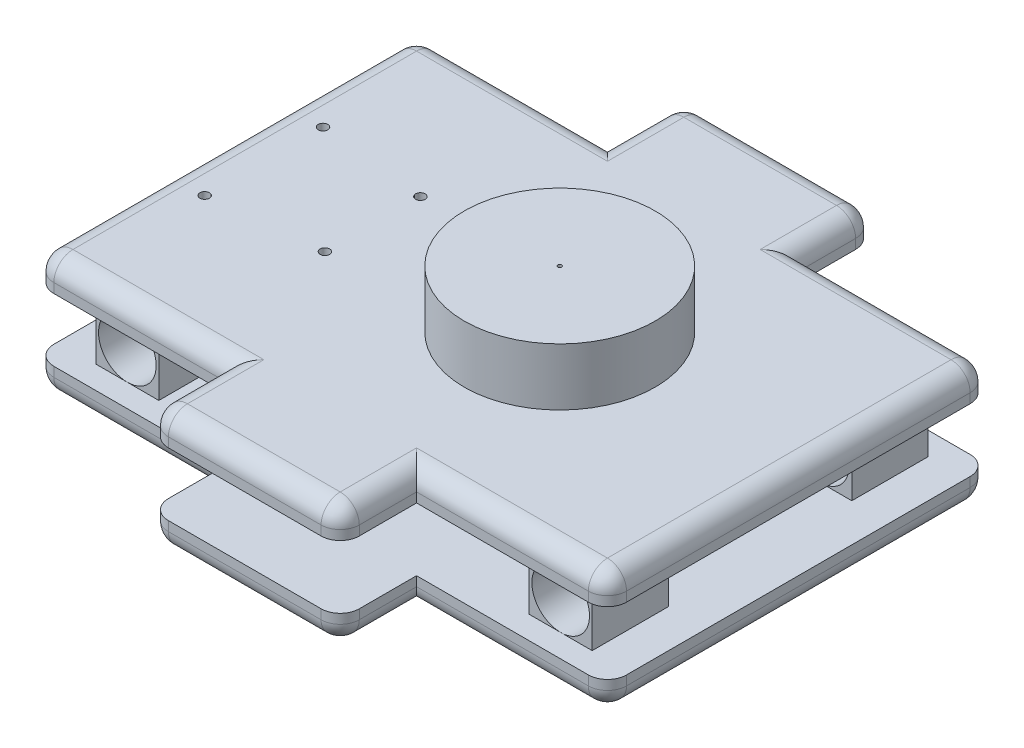
from build123d import *

# Parameters (mm, degrees)
SKETCH1_W                = 300
SKETCH1_H                = 200
BOSS_EXTRUDE1_DEPTH      = 15
SKETCH3_W                = 33
SKETCH3_H                = 40
BOSS_EXTRUDE2_DEPTH      = 33
SKETCH4_R                = 15.1
CUT_EXTRUDE1_DEPTH       = 222
SKETCH5_W                = 300
SKETCH5_H                = 200
BOSS_EXTRUDE3_DEPTH      = 15
SKETCH6_W                = 100
SKETCH6_H                = 15
BOSS_EXTRUDE4_DEPTH      = 40
BOSS_EXTRUDE4_DEPTH_BACK = 240
FILLET1_R                = 10
BOSS_EXTRUDE7_DEPTH      = 34
FILLET2_R                = 10
FILLET3_R                = 10
SKETCH12_R               = 1
CUT_EXTRUDE4_DEPTH       = 1
SKETCH13_R               = 2.5
CUT_EXTRUDE5_DEPTH       = 27
SKETCH14_R               = 2.5
CUT_EXTRUDE6_DEPTH       = 32
SKETCH15_R               = 50
BOSS_EXTRUDE9_DEPTH      = 30
SKETCH16_R               = 1
CUT_EXTRUDE7_DEPTH       = 63


with BuildPart() as part:
    # Sketch1 → Boss-Extrude1 (new body)
    with BuildSketch(Plane(origin=(0, 0, 0), x_dir=(1, 0, 0), z_dir=(0, 1, 0))):
        with Locations((150, -100)):
            Rectangle(SKETCH1_W, SKETCH1_H)
    extrude(amount=BOSS_EXTRUDE1_DEPTH)

    # Sketch3 → Boss-Extrude2 (add)
    with BuildSketch(Plane(origin=(0, 15, 0), x_dir=(1, 0, 0), z_dir=(0, 1, 0))):
        with Locations((263.5, -168)):
            Rectangle(SKETCH3_W, SKETCH3_H)
        with Locations((263.5, -32)):
            Rectangle(SKETCH3_W, SKETCH3_H)
        with Locations((36.5, -32)):
            Rectangle(SKETCH3_W, SKETCH3_H)
        with Locations((36.5, -168)):
            Rectangle(SKETCH3_W, SKETCH3_H)
    extrude(amount=BOSS_EXTRUDE2_DEPTH)

    # Sketch4 → Cut-Extrude1 (cut)
    with BuildSketch(Plane.XY.offset(188)):
        with Locations((36.5, 30.1)):
            Circle(SKETCH4_R)
        with Locations((263.5, 30.1)):
            Circle(SKETCH4_R)
    extrude(amount=-CUT_EXTRUDE1_DEPTH, mode=Mode.SUBTRACT)

    # Sketch5 → Boss-Extrude3 (add)
    with BuildSketch(Plane(origin=(0, 48, 0), x_dir=(1, 0, 0), z_dir=(0, 1, 0))):
        with Locations((150, -100)):
            Rectangle(SKETCH5_W, SKETCH5_H)
    extrude(amount=BOSS_EXTRUDE3_DEPTH)

    # Sketch6 → Boss-Extrude4 (add, two sides)
    with BuildSketch(Plane(origin=(0, 0, 0), x_dir=(-1, 0, 0), z_dir=(0, 0, -1))) as boss_extrude4_sk:
        with Locations((-150, 55.5)):
            Rectangle(SKETCH6_W, SKETCH6_H)
        with Locations((-150, 7.5)):
            Rectangle(SKETCH6_W, SKETCH6_H)
    extrude(amount=BOSS_EXTRUDE4_DEPTH)
    extrude(boss_extrude4_sk.sketch, amount=-BOSS_EXTRUDE4_DEPTH_BACK)

    # Fillet1
    fillet1_edges = [part.edges().sort_by_distance(p)[0] for p in [
        (100, 55.5, 240),
        (200, 55.5, 240),
        (100, 55.5, -40),
        (200, 55.5, -40),
        (200, 7.5, 240),
        (100, 7.5, 240),
        (200, 7.5, -40),
        (100, 7.5, -40),
        (0, 7.5, 0),
        (300, 7.5, 0),
        (300, 7.5, 200),
        (0, 7.5, 200),
        (0, 55.5, 0),
        (0, 55.5, 200),
        (300, 55.5, 200),
        (300, 55.5, 0),
    ]]
    fillet(fillet1_edges, radius=FILLET1_R)

    # Sketch11 → Boss-Extrude7 (add)
    with BuildSketch(Plane(origin=(0, 15, 0), x_dir=(1, 0, 0), z_dir=(0, 1, 0))):
        Polygon((0, -82.3), (0, -100), (0, -117.7), (10, -117.7), (10, -82.3), align=None)
    extrude(amount=BOSS_EXTRUDE7_DEPTH)

    # Fillet2
    fillet2_edges = [part.edges().sort_by_distance(p)[0] for p in [
        (245, 63, 200),
        (55, 63, 0),
        (200, 63, -15),
        (100, 63, -15),
        (245, 63, 0),
        (300, 63, 100),
        (150, 63, -40),
        (0, 63, 100),
        (55, 63, 200),
        (100, 63, 215),
        (150, 63, 240),
        (200, 63, 215),
        (102.928932188, 63, -37.071067812),
        (197.071067812, 63, -37.071067812),
        (102.928932188, 63, 237.071067812),
        (197.071067812, 63, 237.071067812),
        (297.071067812, 63, 197.071067812),
        (2.928932188, 63, 197.071067812),
        (2.928932188, 63, 2.928932188),
        (297.071067812, 63, 2.928932188),
    ]]
    fillet(fillet2_edges, radius=FILLET2_R)

    # Fillet3
    fillet3_edges = [part.edges().sort_by_distance(p)[0] for p in [
        (55, 0, 0),
        (245, 0, 200),
        (100, 0, -15),
        (200, 0, -15),
        (245, 0, 0),
        (150, 0, -40),
        (300, 0, 100),
        (200, 0, 215),
        (150, 0, 240),
        (100, 0, 215),
        (55, 0, 200),
        (0, 0, 100),
        (197.071067812, 0, -37.071067812),
        (102.928932188, 0, -37.071067812),
        (102.928932188, 0, 237.071067812),
        (197.071067812, 0, 237.071067812),
        (297.071067812, 0, 197.071067812),
        (2.928932188, 0, 197.071067812),
        (2.928932188, 0, 2.928932188),
        (297.071067812, 0, 2.928932188),
    ]]
    fillet(fillet3_edges, radius=FILLET3_R)

    # Sketch12 → Cut-Extrude4 (cut)
    with BuildSketch(Plane.ZY):
        with Locations((100, 31.5)):
            Circle(SKETCH12_R)
    extrude(amount=-CUT_EXTRUDE4_DEPTH, mode=Mode.SUBTRACT)

    # Sketch13 → Cut-Extrude5 (cut)
    with BuildSketch(Plane(origin=(0, 63, 0), x_dir=(1, 0, 0), z_dir=(0, 1, 0))):
        with Locations((150, -100)):
            Circle(SKETCH13_R)
    extrude(amount=-CUT_EXTRUDE5_DEPTH, mode=Mode.SUBTRACT)

    # Sketch14 → Cut-Extrude6 (cut)
    with BuildSketch(Plane(origin=(0, 63, 0), x_dir=(1, 0, 0), z_dir=(0, 1, 0))):
        with Locations((20, -131)):
            Circle(SKETCH14_R)
        with Locations((20, -69)):
            Circle(SKETCH14_R)
        with Locations((77, -75)):
            Circle(SKETCH14_R)
        with Locations((77, -125)):
            Circle(SKETCH14_R)
    extrude(amount=-CUT_EXTRUDE6_DEPTH, mode=Mode.SUBTRACT)

    # Sketch15 → Boss-Extrude9 (add)
    with BuildSketch(Plane(origin=(0, 63, 0), x_dir=(1, 0, 0), z_dir=(0, 1, 0))):
        with Locations((175, -100)):
            Circle(SKETCH15_R)
    extrude(amount=BOSS_EXTRUDE9_DEPTH)

    # Sketch16 → Cut-Extrude7 (cut)
    with BuildSketch(Plane(origin=(0, 93, 0), x_dir=(1, 0, 0), z_dir=(0, 1, 0))):
        with Locations((175, -100)):
            Circle(SKETCH16_R)
    extrude(amount=-CUT_EXTRUDE7_DEPTH, mode=Mode.SUBTRACT)


solid = part.part
